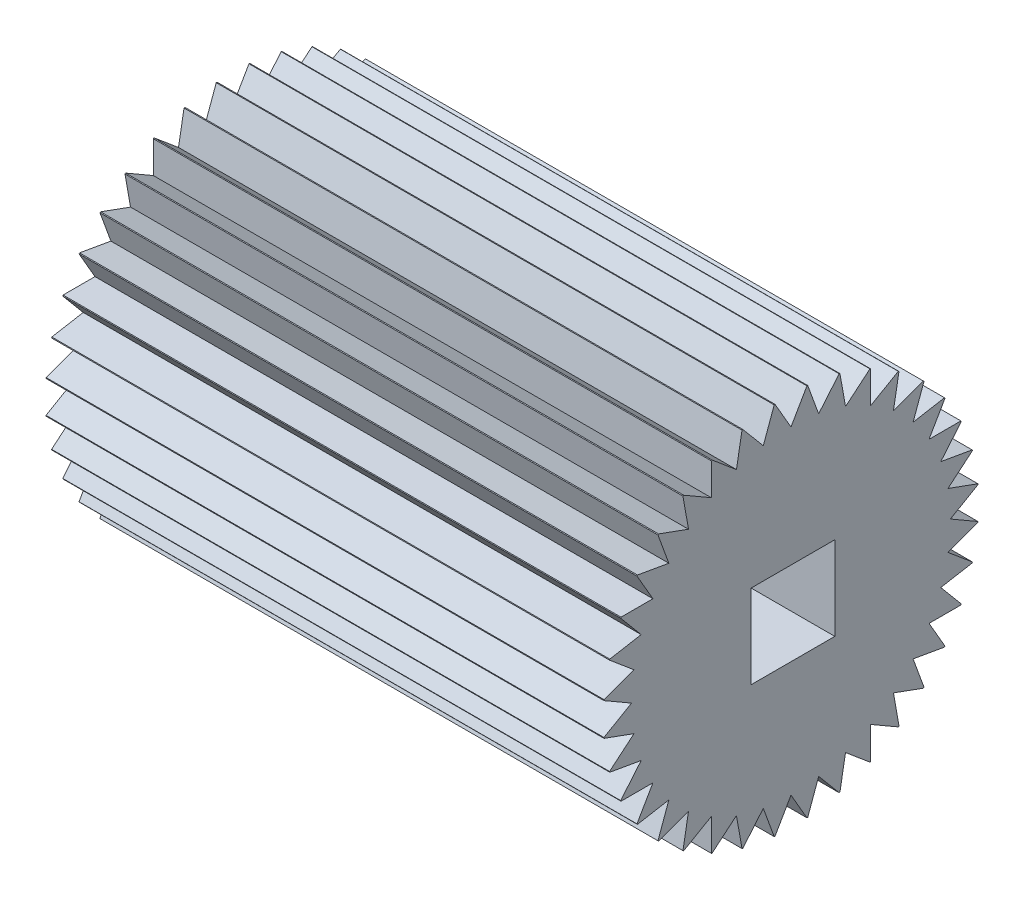
from build123d import *

# Parameters (mm, degrees)
BOSS_EXTRUDE1_DEPTH = 35
SKETCH3_W           = 5.25
SKETCH3_H           = 5.25
CUT_EXTRUDE2_DEPTH  = 10.2
CUT_EXTRUDE3_START  = -35
SKETCH3_2_W         = 5.25
SKETCH3_2_H         = 5.25
CUT_EXTRUDE3_DEPTH  = 10


with BuildPart() as part:
    # Sketch1 → Boss-Extrude1 (new body)
    with BuildSketch(Plane(origin=(0, 0, 0), x_dir=(0, 0, -1), z_dir=(1, 0, 0))):
        with BuildLine():
            Line((-1, 11.732050808), (0, 10))
            Line((0, 10), (1, 11.732050808))
            ThreePointArc((1, 11.732050808), (1.026223309, 11.729786097), (1.05244149, 11.727462772))
            Line((1.05244149, 11.727462772), (1.736481777, 9.84807753))
            Line((1.736481777, 9.84807753), (3.022056996, 11.380166416))
            ThreePointArc((3.022056996, 11.380166416), (3.047488651, 11.373382482), (3.072905078, 11.366541714))
            Line((3.072905078, 11.366541714), (3.420201433, 9.396926208))
            Line((3.420201433, 9.396926208), (4.952290319, 10.682501427))
            ThreePointArc((4.952290319, 10.682501427), (4.976157593, 10.671404395), (5, 10.660254038))
            Line((5, 10.660254038), (5, 8.660254038))
            Line((5, 8.660254038), (6.732050808, 9.660254038))
            ThreePointArc((6.732050808, 9.660254038), (6.753628504, 9.645181086), (6.775172452, 9.630059937))
            Line((6.775172452, 9.630059937), (6.427876097, 7.660444431))
            Line((6.427876097, 7.660444431), (8.307261338, 8.344484718))
            ThreePointArc((8.307261338, 8.344484718), (8.32589383, 8.32589383), (8.344484718, 8.307261338))
            Line((8.344484718, 8.307261338), (7.660444431, 6.427876097))
            Line((7.660444431, 6.427876097), (9.630059937, 6.775172452))
            ThreePointArc((9.630059937, 6.775172452), (9.645181086, 6.753628504), (9.660254038, 6.732050808))
            Line((9.660254038, 6.732050808), (8.660254038, 5))
            Line((8.660254038, 5), (10.660254038, 5))
            ThreePointArc((10.660254038, 5), (10.671404395, 4.976157593), (10.682501427, 4.952290319))
            Line((10.682501427, 4.952290319), (9.396926208, 3.420201433))
            Line((9.396926208, 3.420201433), (11.366541714, 3.072905078))
            ThreePointArc((11.366541714, 3.072905078), (11.373382482, 3.047488651), (11.380166416, 3.022056996))
            Line((11.380166416, 3.022056996), (9.84807753, 1.736481777))
            Line((9.84807753, 1.736481777), (11.727462772, 1.05244149))
            ThreePointArc((11.727462772, 1.05244149), (11.729786097, 1.026223309), (11.732050808, 1))
            Line((11.732050808, 1), (10, 0))
            Line((10, 0), (11.732050808, -1))
            ThreePointArc((11.732050808, -1), (11.729786097, -1.026223309), (11.727462772, -1.05244149))
            Line((11.727462772, -1.05244149), (9.84807753, -1.736481777))
            Line((9.84807753, -1.736481777), (11.380166416, -3.022056996))
            ThreePointArc((11.380166416, -3.022056996), (11.373382482, -3.047488651), (11.366541714, -3.072905078))
            Line((11.366541714, -3.072905078), (9.396926208, -3.420201433))
            Line((9.396926208, -3.420201433), (10.682501427, -4.952290319))
            ThreePointArc((10.682501427, -4.952290319), (10.671404395, -4.976157593), (10.660254038, -5))
            Line((10.660254038, -5), (8.660254038, -5))
            Line((8.660254038, -5), (9.660254038, -6.732050808))
            ThreePointArc((9.660254038, -6.732050808), (9.645181086, -6.753628504), (9.630059937, -6.775172452))
            Line((9.630059937, -6.775172452), (7.660444431, -6.427876097))
            Line((7.660444431, -6.427876097), (8.344484718, -8.307261338))
            ThreePointArc((8.344484718, -8.307261338), (8.32589383, -8.32589383), (8.307261338, -8.344484718))
            Line((8.307261338, -8.344484718), (6.427876097, -7.660444431))
            Line((6.427876097, -7.660444431), (6.775172452, -9.630059937))
            ThreePointArc((6.775172452, -9.630059937), (6.753628504, -9.645181086), (6.732050808, -9.660254038))
            Line((6.732050808, -9.660254038), (5, -8.660254038))
            Line((5, -8.660254038), (5, -10.660254038))
            ThreePointArc((5, -10.660254038), (4.976157593, -10.671404395), (4.952290319, -10.682501427))
            Line((4.952290319, -10.682501427), (3.420201433, -9.396926208))
            Line((3.420201433, -9.396926208), (3.072905078, -11.366541714))
            ThreePointArc((3.072905078, -11.366541714), (3.047488651, -11.373382482), (3.022056996, -11.380166416))
            Line((3.022056996, -11.380166416), (1.736481777, -9.84807753))
            Line((1.736481777, -9.84807753), (1.05244149, -11.727462772))
            ThreePointArc((1.05244149, -11.727462772), (1.026223309, -11.729786097), (1, -11.732050808))
            Line((1, -11.732050808), (0, -10))
            Line((0, -10), (-1, -11.732050808))
            ThreePointArc((-1, -11.732050808), (-1.026223309, -11.729786097), (-1.05244149, -11.727462772))
            Line((-1.05244149, -11.727462772), (-1.736481777, -9.84807753))
            Line((-1.736481777, -9.84807753), (-3.022056996, -11.380166416))
            ThreePointArc((-3.022056996, -11.380166416), (-3.047488651, -11.373382482), (-3.072905078, -11.366541714))
            Line((-3.072905078, -11.366541714), (-3.420201433, -9.396926208))
            Line((-3.420201433, -9.396926208), (-4.952290319, -10.682501427))
            ThreePointArc((-4.952290319, -10.682501427), (-4.976157593, -10.671404395), (-5, -10.660254038))
            Line((-5, -10.660254038), (-5, -8.660254038))
            Line((-5, -8.660254038), (-6.732050808, -9.660254038))
            ThreePointArc((-6.732050808, -9.660254038), (-6.753628504, -9.645181086), (-6.775172452, -9.630059937))
            Line((-6.775172452, -9.630059937), (-6.427876097, -7.660444431))
            Line((-6.427876097, -7.660444431), (-8.307261338, -8.344484718))
            ThreePointArc((-8.307261338, -8.344484718), (-8.32589383, -8.32589383), (-8.344484718, -8.307261338))
            Line((-8.344484718, -8.307261338), (-7.660444431, -6.427876097))
            Line((-7.660444431, -6.427876097), (-9.630059937, -6.775172452))
            ThreePointArc((-9.630059937, -6.775172452), (-9.645181086, -6.753628504), (-9.660254038, -6.732050808))
            Line((-9.660254038, -6.732050808), (-8.660254038, -5))
            Line((-8.660254038, -5), (-10.660254038, -5))
            ThreePointArc((-10.660254038, -5), (-10.671404395, -4.976157593), (-10.682501427, -4.952290319))
            Line((-10.682501427, -4.952290319), (-9.396926208, -3.420201433))
            Line((-9.396926208, -3.420201433), (-11.366541714, -3.072905078))
            ThreePointArc((-11.366541714, -3.072905078), (-11.373382482, -3.047488651), (-11.380166416, -3.022056996))
            Line((-11.380166416, -3.022056996), (-9.84807753, -1.736481777))
            Line((-9.84807753, -1.736481777), (-11.727462772, -1.05244149))
            ThreePointArc((-11.727462772, -1.05244149), (-11.729786097, -1.026223309), (-11.732050808, -1))
            Line((-11.732050808, -1), (-10, 0))
            Line((-10, 0), (-11.732050808, 1))
            ThreePointArc((-11.732050808, 1), (-11.729786097, 1.026223309), (-11.727462772, 1.05244149))
            Line((-11.727462772, 1.05244149), (-9.84807753, 1.736481777))
            Line((-9.84807753, 1.736481777), (-11.380166416, 3.022056996))
            ThreePointArc((-11.380166416, 3.022056996), (-11.373382482, 3.047488651), (-11.366541714, 3.072905078))
            Line((-11.366541714, 3.072905078), (-9.396926208, 3.420201433))
            Line((-9.396926208, 3.420201433), (-10.682501427, 4.952290319))
            ThreePointArc((-10.682501427, 4.952290319), (-10.671404395, 4.976157593), (-10.660254038, 5))
            Line((-10.660254038, 5), (-8.660254038, 5))
            Line((-8.660254038, 5), (-9.660254038, 6.732050808))
            ThreePointArc((-9.660254038, 6.732050808), (-9.645181086, 6.753628504), (-9.630059937, 6.775172452))
            Line((-9.630059937, 6.775172452), (-7.660444431, 6.427876097))
            Line((-7.660444431, 6.427876097), (-8.344484718, 8.307261338))
            ThreePointArc((-8.344484718, 8.307261338), (-8.32589383, 8.32589383), (-8.307261338, 8.344484718))
            Line((-8.307261338, 8.344484718), (-6.427876097, 7.660444431))
            Line((-6.427876097, 7.660444431), (-6.775172452, 9.630059937))
            ThreePointArc((-6.775172452, 9.630059937), (-6.753628504, 9.645181086), (-6.732050808, 9.660254038))
            Line((-6.732050808, 9.660254038), (-5, 8.660254038))
            Line((-5, 8.660254038), (-5, 10.660254038))
            ThreePointArc((-5, 10.660254038), (-4.976157593, 10.671404395), (-4.952290319, 10.682501427))
            Line((-4.952290319, 10.682501427), (-3.420201433, 9.396926208))
            Line((-3.420201433, 9.396926208), (-3.072905078, 11.366541714))
            ThreePointArc((-3.072905078, 11.366541714), (-3.047488651, 11.373382482), (-3.022056996, 11.380166416))
            Line((-3.022056996, 11.380166416), (-1.736481777, 9.84807753))
            Line((-1.736481777, 9.84807753), (-1.05244149, 11.727462772))
            ThreePointArc((-1.05244149, 11.727462772), (-1.026223309, 11.729786097), (-1, 11.732050808))
        make_face()
    extrude(amount=BOSS_EXTRUDE1_DEPTH)

    # Sketch3 → Cut-Extrude2 (cut)
    with BuildSketch(Plane(origin=(35, 0, 0), x_dir=(0, 0, -1), z_dir=(1, 0, 0))):
        with Locations((0.125, -0.125)):
            Rectangle(SKETCH3_W, SKETCH3_H)
    extrude(amount=-CUT_EXTRUDE2_DEPTH, mode=Mode.SUBTRACT)

    # Sketch3_2 → Cut-Extrude3 (cut)
    with BuildSketch(Plane(origin=(35, 0, 0), x_dir=(0, 0, -1), z_dir=(1, 0, 0)).offset(CUT_EXTRUDE3_START)):
        with Locations((0.125, -0.125)):
            Rectangle(SKETCH3_2_W, SKETCH3_2_H)
    extrude(amount=CUT_EXTRUDE3_DEPTH, mode=Mode.SUBTRACT)


solid = part.part
